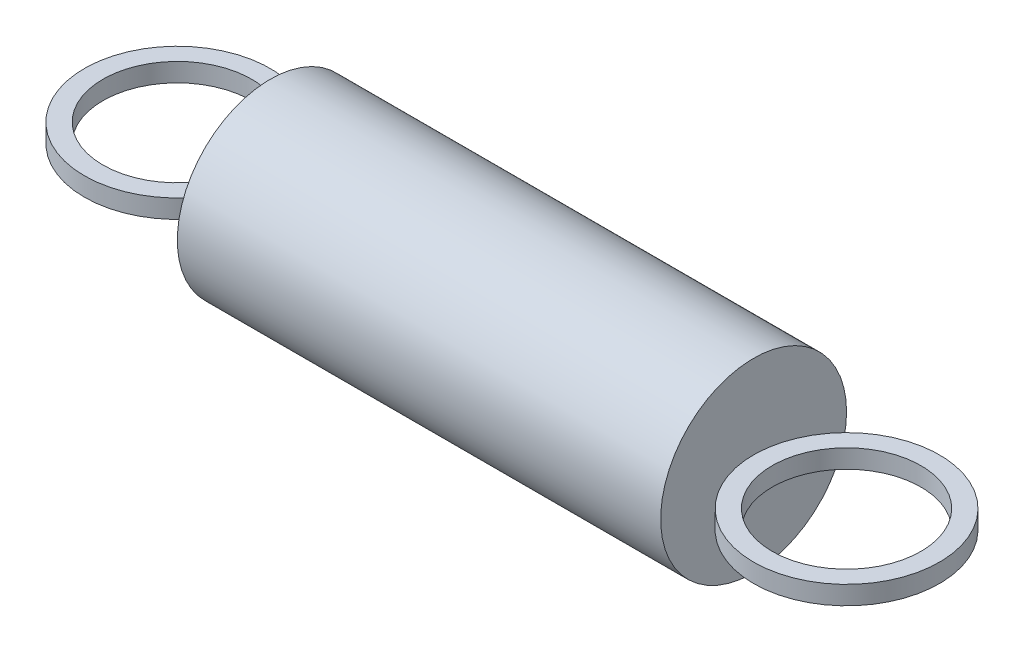
from build123d import *

# Parameters (mm, degrees)
SKETCH1_R             = 3.96875
BOSS_EXTRUDE1_DEPTH   = 20.6375
SKETCH3_R             = 3.96875
SKETCH3_R_2           = 3.175
BOSS_EXTRUDE2_DEPTH   = 0.396875
BOSS_EXTRUDE2_2_DEPTH = 0.396875


with BuildPart() as part:
    # Sketch1 → Boss-Extrude1 (new body)
    with BuildSketch(Plane(origin=(0, 0, 0), x_dir=(0, 0, -1), z_dir=(1, 0, 0))):
        Circle(SKETCH1_R)
    extrude(amount=BOSS_EXTRUDE1_DEPTH)


with BuildPart() as body_2:
    # Sketch3 → Boss-Extrude2 (new body, symmetric)
    with BuildSketch(Plane(origin=(0, 0, 0), x_dir=(1, 0, 0), z_dir=(0, 1, 0))):
        with Locations((-3.96875, 0)):
            Circle(SKETCH3_R)
        with Locations((-3.96875, 0)):
            Circle(SKETCH3_R_2, mode=Mode.SUBTRACT)
    extrude(amount=BOSS_EXTRUDE2_DEPTH, both=True)


with BuildPart() as body_3:
    # Sketch3 → Boss-Extrude2 2 (new body, symmetric)
    with BuildSketch(Plane(origin=(0, 0, 0), x_dir=(1, 0, 0), z_dir=(0, 1, 0))):
        with Locations((24.60625, 0)):
            Circle(SKETCH3_R)
        with Locations((24.60625, 0)):
            Circle(SKETCH3_R_2, mode=Mode.SUBTRACT)
    extrude(amount=BOSS_EXTRUDE2_2_DEPTH, both=True)


solid = Compound([part.part, body_2.part, body_3.part])
